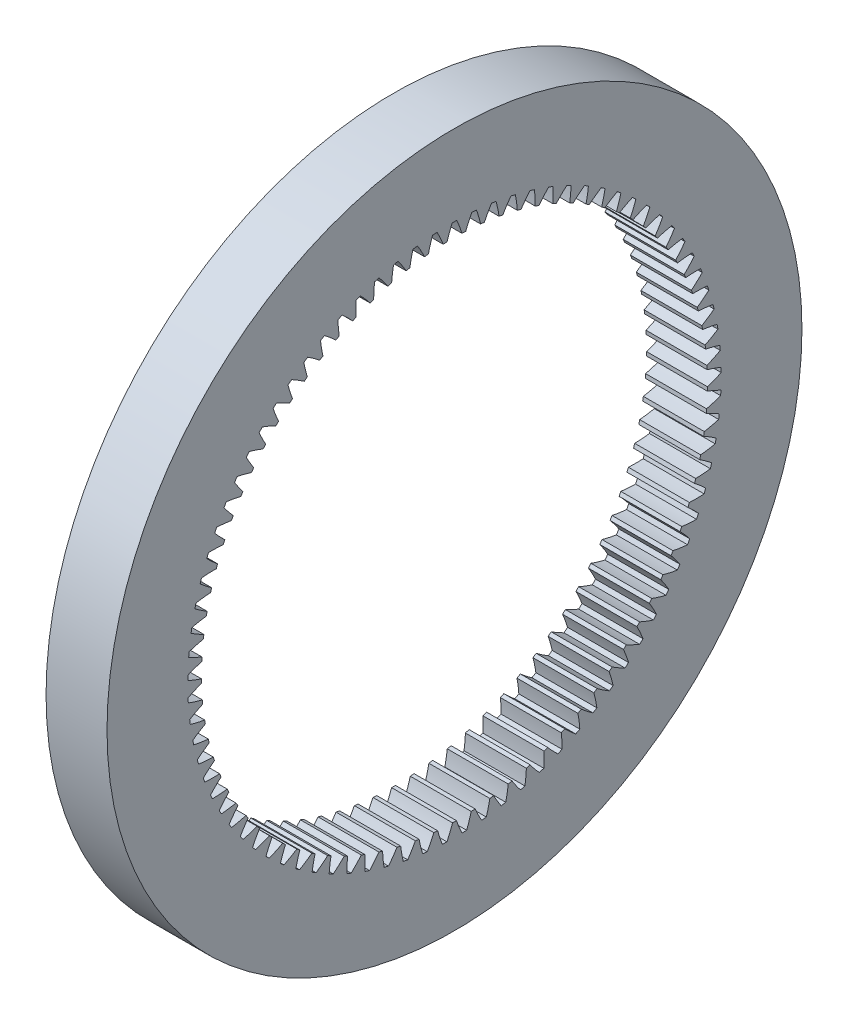
from build123d import *

# Parameters (mm, degrees)
BASPROSKE_W     = 5
BASPROSKE_H     = 7.75
TOOTHCUT_DEPTH  = 41.614036982
TEETHCUTS_COUNT = 85
TEETHCUTS_ANGLE = 355.764705882


with BuildPart() as part:
    # BasProSke → Base-Revolve (revolve)
    with BuildSketch(Plane(origin=(0, 0, 0), x_dir=(1, 0, 0), z_dir=(0, 1, 0))):
        with Locations((2.5, 24.625)):
            Rectangle(BASPROSKE_W, BASPROSKE_H)
    revolve(axis=Axis((-10, 0, 0), (1, 0, 0)))

    # TooCutSke → ToothCut (cut, through all)
    with BuildSketch(Plane(origin=(0, 0, 0), x_dir=(0, 0, -1), z_dir=(1, 0, 0))):
        with BuildLine():
            ThreePointArc((0.616316445, 20.71543384), (0.419709424, 21.301520253), (0.189349907, 21.875180516))
            ThreePointArc((0.189349907, 21.875180516), (0, 21.876), (-0.189349907, 21.875180516))
            ThreePointArc((-0.189349907, 21.875180516), (-0.419709424, 21.301520253), (-0.616316445, 20.71543384))
            ThreePointArc((-0.616316445, 20.71543384), (0, 20.7246), (0.616316445, 20.71543384))
        make_face()
    toothcut = extrude(amount=TOOTHCUT_DEPTH, mode=Mode.SUBTRACT)

    # TeethCuts: ToothCut ×85 about axis
    teethcuts_axis = Axis((-10, 0, 0), (1, 0, 0))
    for i in range(1, TEETHCUTS_COUNT):
        add(toothcut.rotate(teethcuts_axis, i * TEETHCUTS_ANGLE / (TEETHCUTS_COUNT - 1)), mode=Mode.SUBTRACT)


solid = part.part
